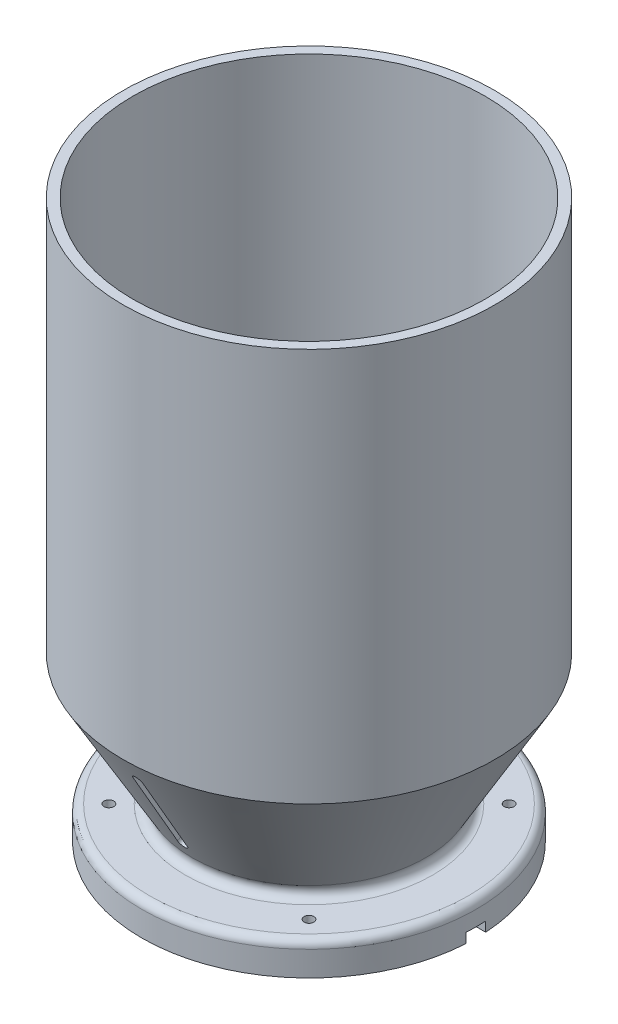
from build123d import *

# Parameters (mm, degrees)
HOPPERBASELOCKNOTCH_W     = 10
HOPPERBASELOCKNOTCH_H     = 5
CUT_EXTRUDE_1_DEPTH       = 96
CUT_EXTRUDE_1_DEPTH_BACK  = 96
HOPPERTANK_R              = 95
HOPPERTANK_R_2            = 90
BOSS_EXTRUDE_1_DEPTH      = 200
FILLET3_R                 = 4
CUT_EXTRUDE1_REACH        = 267.215
F_5_0MM_DOWEL_HOLE1_D     = 5
F_5_0MM_DOWEL_HOLE1_DEPTH = 16.7


with BuildPart() as part:
    # hopperBase → Revolve-Boss-1 (revolve)
    with BuildSketch(Plane.XY):
        Polygon((50.5, 0), (55.5, 0), (55.5, -5), (85.5, -5), (85.5, 11.7), (56.273502692, 11.7), (95, 78.776260937), (95, 80.116006899), (90, 80.116006899), (50.5, 11.7), align=None)
    revolve(axis=Axis((0, 0, 0), (0, 1, 0)))

    # hopperBaseLockNotch → Cut-Extrude-1 (cut, two sides)
    with BuildSketch(Plane(origin=(0, 0, 0), x_dir=(0, 0, -1), z_dir=(1, 0, 0))) as cut_extrude_1_sk:
        with Locations((0, -2.5)):
            Rectangle(HOPPERBASELOCKNOTCH_W, HOPPERBASELOCKNOTCH_H)
    extrude(amount=CUT_EXTRUDE_1_DEPTH, mode=Mode.SUBTRACT)
    extrude(cut_extrude_1_sk.sketch, amount=-CUT_EXTRUDE_1_DEPTH_BACK, mode=Mode.SUBTRACT)

    # hopperTank → Boss-Extrude-1 (add)
    with BuildSketch(Plane(origin=(0, 80.116006899, 0), x_dir=(1, 0, 0), z_dir=(0, 1, 0))):
        Circle(HOPPERTANK_R)
        Circle(HOPPERTANK_R_2, mode=Mode.SUBTRACT)
    extrude(amount=BOSS_EXTRUDE_1_DEPTH)

    # Fillet3
    fillet3_edges = [part.edges().sort_by_distance(p)[0] for p in [
        (-85.5, 11.7, 0),
        (-56.273502692, 11.7, 0),
    ]]
    fillet(fillet3_edges, radius=FILLET3_R)

    # Sketch33 → Cut-Extrude1 (cut, up to next)
    with BuildSketch(Plane(origin=(0, -21.442141446, 37.138878407), x_dir=(1, 0, 0), z_dir=(0, -0.5, 0.866025404)), mode=Mode.PRIVATE) as cut_extrude1_sk1:
        with BuildLine():
            Line((2.5, 100.722243186), (2.5, 55.197451801))
            ThreePointArc((2.5, 55.197451801), (0, 52.697451801), (-2.5, 55.197451801))
            Line((-2.5, 55.197451801), (-2.5, 100.722243186))
            ThreePointArc((-2.5, 100.722243186), (0, 103.222243186), (2.5, 100.722243186))
        make_face()
    cut_extrude1_tool1 = extrude(cut_extrude1_sk1.sketch, amount=-CUT_EXTRUDE1_REACH, mode=Mode.PRIVATE) & part.part
    add(cut_extrude1_tool1.solids().sort_by_distance((0, 46.073067, 76.118802))[0], mode=Mode.SUBTRACT)

    # Ø5.0mm Dowel Hole1
    with Locations(Plane(origin=(0, 11.7, 0), x_dir=(1, 0, 0), z_dir=(0, 1, 0))):
        with Locations((-51.159778753, -51.159778753), (51.159778753, -51.159778753), (51.159778753, 51.159778753), (-51.159778753, 51.159778753)):
            Hole(F_5_0MM_DOWEL_HOLE1_D / 2, depth=F_5_0MM_DOWEL_HOLE1_DEPTH)


solid = part.part
